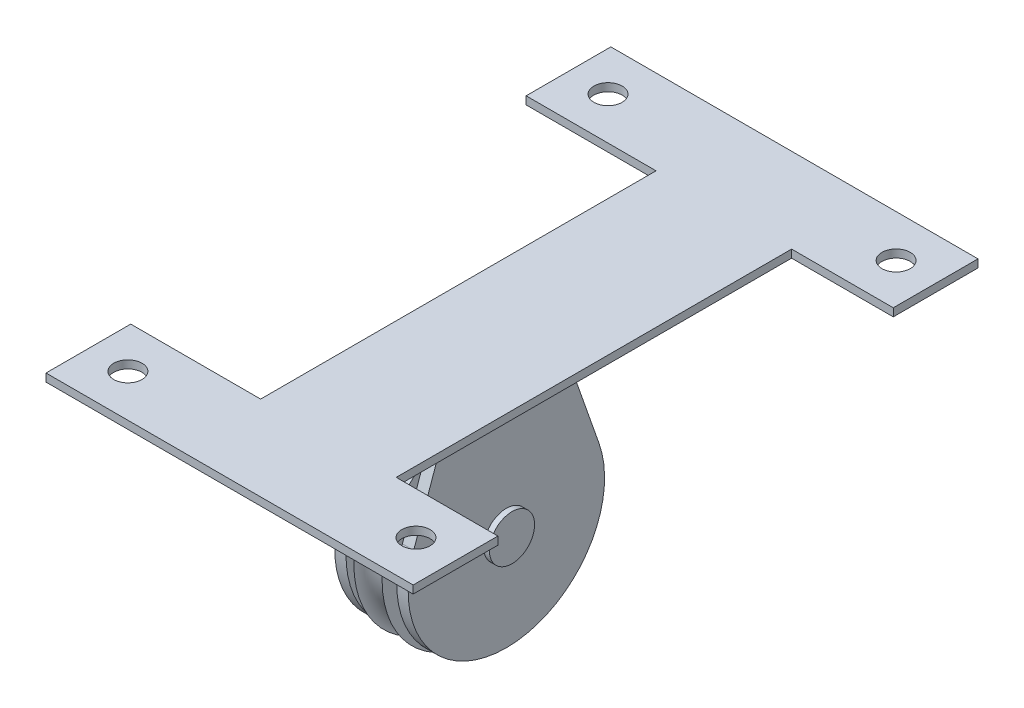
from build123d import *

# Parameters (mm, degrees)
SKETCH2_R           = 5.08
BOSS_EXTRUDE1_DEPTH = 2.54
BOSS_EXTRUDE2_DEPTH = 1.778
SKETCH4_R           = 3.175
CUT_EXTRUDE2_DEPTH  = 2.778
SKETCH6_R           = 5.08
BOSS_EXTRUDE4_DEPTH = 9.525


with BuildPart() as part:
    # Sketch1 → Revolve1 (revolve)
    with BuildSketch(Plane.XY):
        with BuildLine():
            Line((-3.175, 5.08), (3.175, 5.08))
            Line((3.175, 5.08), (3.175, 22.86))
            ThreePointArc((3.175, 22.86), (0, 19.685), (-3.175, 22.86))
            Line((-3.175, 22.86), (-3.175, 5.08))
        make_face()
    revolve(axis=Axis((0, 0, 0), (1, 0, 0)))

    # Sketch6 → Boss-Extrude4 (add, symmetric)
    with BuildSketch(Plane(origin=(0, 0, 0), x_dir=(0, 0, -1), z_dir=(1, 0, 0))):
        Circle(SKETCH6_R)
    extrude(amount=BOSS_EXTRUDE4_DEPTH, both=True)


with BuildPart() as body_2:
    # Sketch2 → Boss-Extrude1 (new body)
    with BuildSketch(Plane(origin=(5.715, 0, 0), x_dir=(0, 0, -1), z_dir=(1, 0, 0))):
        with BuildLine():
            Line((-20.836536434, 7.320381186), (-12.7, 30.48))
            Line((-12.7, 30.48), (12.7, 30.48))
            Line((12.7, 30.48), (20.836536434, 7.320381186))
            ThreePointArc((20.836536434, 7.320381186), (0, -22.085045421), (-20.836536434, 7.320381186))
        make_face()
        Circle(SKETCH2_R, mode=Mode.SUBTRACT)
    extrude(amount=BOSS_EXTRUDE1_DEPTH)


with BuildPart() as body_3:
    # Mirror2: mirrored copy
    add(body_2.part.mirror(Plane(origin=(0, 0, 0), x_dir=(0, 0, 1), z_dir=(1, 0, 0))))


with BuildPart() as body_2_1:
    add(body_2.part)

    add(body_3.part)  # Boss-Extrude2 merges body 3
    # Sketch3 → Boss-Extrude2 (add)
    with BuildSketch(Plane(origin=(0, 30.48, 0), x_dir=(1, 0, 0), z_dir=(0, 1, 0))):
        Polygon((15.24, 57.15), (15.24, -31.75), (38.1, -31.75), (38.1, -50.8), (-44.45, -50.8), (-44.45, -31.75), (-15.24, -31.75), (-15.24, 57.15), (-44.45, 57.15), (-44.45, 76.2), (38.1, 76.2), (38.1, 57.15), align=None)
    extrude(amount=-BOSS_EXTRUDE2_DEPTH)

    # Sketch4 → Cut-Extrude2 (cut, through all)
    with BuildSketch(Plane(origin=(0, 28.702, 0), x_dir=(-1, 0, 0), z_dir=(0, -1, 0))):
        with Locations((-29.21, -41.275)):
            Circle(SKETCH4_R)
        with Locations((35.56, -41.275)):
            Circle(SKETCH4_R)
        with Locations((-29.21, 66.675)):
            Circle(SKETCH4_R)
        with Locations((35.56, 66.675)):
            Circle(SKETCH4_R)
    extrude(amount=-CUT_EXTRUDE2_DEPTH, mode=Mode.SUBTRACT)


solid = Compound([part.part, body_2_1.part])
